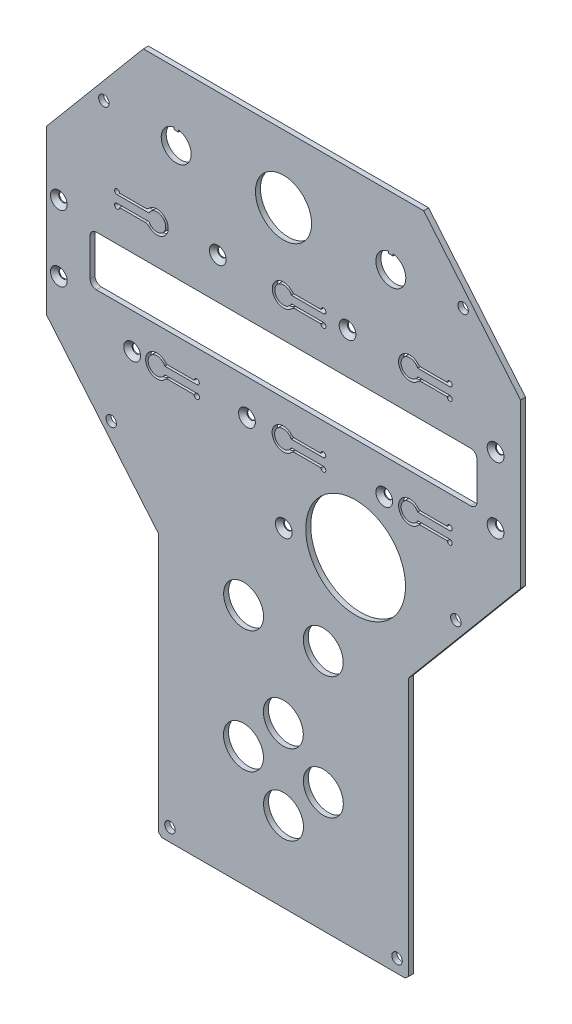
from build123d import *

# Parameters (mm, degrees)
RESSALTO_EXTRUS_O1_DEPTH                      = 2
CORTE_EXTRUS_O1_REACH                         = 4
ESBO_O2_R                                     = 2.1
CORTE_EXTRUS_O2_REACH                         = 4
CORTE_EXTRUS_O3_REACH                         = 4
ESBO_O4_R                                     = 20
CORTE_EXTRUS_O4_REACH                         = 4
ESBO_O5_R                                     = 8
ESBO_O5_R_2                                   = 11.25
ESCAREADO_PARA_PARAFUSO_ALLEN_SEXTAV_2_COUNT  = 2
ESCAREADO_PARA_PARAFUSO_ALLEN_SEXTAV_2_PITCH  = 26.5
ESCAREADO_PARA_PARAFUSO_ALLEN_SEXTAV_3_COUNT  = 2
ESCAREADO_PARA_PARAFUSO_ALLEN_SEXTAV_3_PITCH  = 47.918783057
ESCAREADO_PARA_PARAFUSO_ALLEN_SEXTAV_4_COUNT  = 2
ESCAREADO_PARA_PARAFUSO_ALLEN_SEXTAV_4_PITCH  = 84.354894452
ESCAREADO_PARA_PARAFUSO_ALLEN_SEXTAV_5_COUNT  = 2
ESCAREADO_PARA_PARAFUSO_ALLEN_SEXTAV_5_PITCH  = 135.769067452
ESCAREADO_PARA_PARAFUSO_ALLEN_SEXTAV_6_COUNT  = 2
ESCAREADO_PARA_PARAFUSO_ALLEN_SEXTAV_6_PITCH  = 176.995056428
ESCAREADO_PARA_PARAFUSO_ALLEN_SEXTAV_7_COUNT  = 2
ESCAREADO_PARA_PARAFUSO_ALLEN_SEXTAV_7_PITCH  = 175
ESCAREADO_PARA_PARAFUSO_ALLEN_SEXTAV_8_COUNT  = 2
ESCAREADO_PARA_PARAFUSO_ALLEN_SEXTAV_8_PITCH  = 116.384068539
ESCAREADO_PARA_PARAFUSO_ALLEN_SEXTAV_9_COUNT  = 2
ESCAREADO_PARA_PARAFUSO_ALLEN_SEXTAV_9_PITCH  = 64.945475466
ESCAREADO_PARA_PARAFUSO_ALLEN_SEXTAV_10_COUNT = 2
ESCAREADO_PARA_PARAFUSO_ALLEN_SEXTAV_10_PITCH = 113.39334618
CORTE_EXTRUS_O5_DEPTH                         = 10
FILETE1_R                                     = 2


with BuildPart() as part:
    # Esboço1 → Ressalto-extrusão1 (new body)
    with BuildSketch(Plane.XY):
        Polygon((55.321046002, 133.809611411), (-57.006999458, 133.809611411), (-95.842976728, 87.526695978), (-95.842976728, 22.140182404), (-50.842976728, -31.488729263), (-50.842976728, -135.082673958), (-49.522853837, -136.190388589), (47.836900381, -136.190388589), (49.157023272, -135.082673958), (49.157023272, -31.488729263), (94.157023272, 22.140182404), (94.157023272, 87.526695978), align=None)
    extrude(amount=RESSALTO_EXTRUS_O1_DEPTH)

    # Esboço2 → Corte-extrusão1 (cut, up to next)
    with BuildSketch(Plane.XY.offset(2), mode=Mode.PRIVATE) as corte_extrus_o1_sk1:
        with Locations((-72.814392548, 107.949888211)):
            Circle(ESBO_O2_R)
    corte_extrus_o1_tool1 = extrude(corte_extrus_o1_sk1.sketch, amount=-CORTE_EXTRUS_O1_REACH, mode=Mode.PRIVATE) & part.part
    add(corte_extrus_o1_tool1.solids().sort_by_distance((-72.814393, 107.949888, 2))[0], mode=Mode.SUBTRACT)
    # Esboço2 → Corte-extrusão1 (cut, up to next)
    with BuildSketch(Plane.XY.offset(2), mode=Mode.PRIVATE) as corte_extrus_o1_sk2:
        with Locations((-46.342976728, -130.964393909)):
            Circle(ESBO_O2_R)
    corte_extrus_o1_tool2 = extrude(corte_extrus_o1_sk2.sketch, amount=-CORTE_EXTRUS_O1_REACH, mode=Mode.PRIVATE) & part.part
    add(corte_extrus_o1_tool2.solids().sort_by_distance((-46.342977, -130.964394, 2))[0], mode=Mode.SUBTRACT)
    # Esboço2 → Corte-extrusão1 (cut, up to next)
    with BuildSketch(Plane.XY.offset(2), mode=Mode.PRIVATE) as corte_extrus_o1_sk3:
        with Locations((44.657023272, -130.964393909)):
            Circle(ESBO_O2_R)
    corte_extrus_o1_tool3 = extrude(corte_extrus_o1_sk3.sketch, amount=-CORTE_EXTRUS_O1_REACH, mode=Mode.PRIVATE) & part.part
    add(corte_extrus_o1_tool3.solids().sort_by_distance((44.657023, -130.964394, 2))[0], mode=Mode.SUBTRACT)
    # Esboço2 → Corte-extrusão1 (cut, up to next)
    with BuildSketch(Plane.XY.offset(2), mode=Mode.PRIVATE) as corte_extrus_o1_sk4:
        with Locations((71.128439092, 107.949888211)):
            Circle(ESBO_O2_R)
    corte_extrus_o1_tool4 = extrude(corte_extrus_o1_sk4.sketch, amount=-CORTE_EXTRUS_O1_REACH, mode=Mode.PRIVATE) & part.part
    add(corte_extrus_o1_tool4.solids().sort_by_distance((71.128439, 107.949888, 2))[0], mode=Mode.SUBTRACT)
    # Esboço2 → Corte-extrusão1 (cut, up to next)
    with BuildSketch(Plane.XY.offset(2), mode=Mode.PRIVATE) as corte_extrus_o1_sk5:
        with Locations((-69.895776734, -1.781729186)):
            Circle(ESBO_O2_R)
    corte_extrus_o1_tool5 = extrude(corte_extrus_o1_sk5.sketch, amount=-CORTE_EXTRUS_O1_REACH, mode=Mode.PRIVATE) & part.part
    add(corte_extrus_o1_tool5.solids().sort_by_distance((-69.895777, -1.781729, 2))[0], mode=Mode.SUBTRACT)
    # Esboço2 → Corte-extrusão1 (cut, up to next)
    with BuildSketch(Plane.XY.offset(2), mode=Mode.PRIVATE) as corte_extrus_o1_sk6:
        with Locations((68.209823278, -1.781729186)):
            Circle(ESBO_O2_R)
    corte_extrus_o1_tool6 = extrude(corte_extrus_o1_sk6.sketch, amount=-CORTE_EXTRUS_O1_REACH, mode=Mode.PRIVATE) & part.part
    add(corte_extrus_o1_tool6.solids().sort_by_distance((68.209823, -1.781729, 2))[0], mode=Mode.SUBTRACT)

    # Esboço3 → Corte-extrusão2 (cut, up to next)
    with BuildSketch(Plane.XY.offset(2), mode=Mode.PRIVATE) as corte_extrus_o2_sk1:
        with BuildLine():
            Line((-75.842976728, 40.809611411), (74.157023272, 40.809611411))
            ThreePointArc((74.157023272, 40.809611411), (75.924790225, 41.541844458), (76.657023272, 43.309611411))
            Line((76.657023272, 43.309611411), (76.657023272, 58.309611411))
            ThreePointArc((76.657023272, 58.309611411), (75.924790225, 60.077378364), (74.157023272, 60.809611411))
            Line((74.157023272, 60.809611411), (-75.842976728, 60.809611411))
            ThreePointArc((-75.842976728, 60.809611411), (-77.610743681, 60.077378364), (-78.342976728, 58.309611411))
            Line((-78.342976728, 58.309611411), (-78.342976728, 43.309611411))
            ThreePointArc((-78.342976728, 43.309611411), (-77.610743681, 41.541844458), (-75.842976728, 40.809611411))
        make_face()
    corte_extrus_o2_tool1 = extrude(corte_extrus_o2_sk1.sketch, amount=-CORTE_EXTRUS_O2_REACH, mode=Mode.PRIVATE) & part.part
    add(corte_extrus_o2_tool1.solids().sort_by_distance((-0.842977, 50.809611, 2))[0], mode=Mode.SUBTRACT)

    # Esboço4 → Corte-extrusão3 (cut, up to next)
    with BuildSketch(Plane.XY.offset(2), mode=Mode.PRIVATE) as corte_extrus_o3_sk1:
        with Locations((28.056326272, -0.190388589)):
            Circle(ESBO_O4_R)
    corte_extrus_o3_tool1 = extrude(corte_extrus_o3_sk1.sketch, amount=-CORTE_EXTRUS_O3_REACH, mode=Mode.PRIVATE) & part.part
    add(corte_extrus_o3_tool1.solids().sort_by_distance((28.056326, -0.190389, 2))[0], mode=Mode.SUBTRACT)

    # Esboço5 → Corte-extrusão4 (cut, up to next)
    with BuildSketch(Plane.XY.offset(2), mode=Mode.PRIVATE) as corte_extrus_o4_sk1:
        with Locations((-16.894876728, -88.105888589)):
            Circle(ESBO_O5_R)
    corte_extrus_o4_tool1 = extrude(corte_extrus_o4_sk1.sketch, amount=-CORTE_EXTRUS_O4_REACH, mode=Mode.PRIVATE) & part.part
    add(corte_extrus_o4_tool1.solids().sort_by_distance((-16.894877, -88.105889, 2))[0], mode=Mode.SUBTRACT)
    # Esboço5 → Corte-extrusão4 (cut, up to next)
    with BuildSketch(Plane.XY.offset(2), mode=Mode.PRIVATE) as corte_extrus_o4_sk2:
        with Locations((15.122923272, -88.105888589)):
            Circle(ESBO_O5_R)
    corte_extrus_o4_tool2 = extrude(corte_extrus_o4_sk2.sketch, amount=-CORTE_EXTRUS_O4_REACH, mode=Mode.PRIVATE) & part.part
    add(corte_extrus_o4_tool2.solids().sort_by_distance((15.122923, -88.105889, 2))[0], mode=Mode.SUBTRACT)
    # Esboço5 → Corte-extrusão4 (cut, up to next)
    with BuildSketch(Plane.XY.offset(2), mode=Mode.PRIVATE) as corte_extrus_o4_sk3:
        with Locations((-0.842976728, -104.141188589)):
            Circle(ESBO_O5_R)
    corte_extrus_o4_tool3 = extrude(corte_extrus_o4_sk3.sketch, amount=-CORTE_EXTRUS_O4_REACH, mode=Mode.PRIVATE) & part.part
    add(corte_extrus_o4_tool3.solids().sort_by_distance((-0.842977, -104.141189, 2))[0], mode=Mode.SUBTRACT)
    # Esboço5 → Corte-extrusão4 (cut, up to next)
    with BuildSketch(Plane.XY.offset(2), mode=Mode.PRIVATE) as corte_extrus_o4_sk4:
        with Locations((-0.909676728, -72.123388589)):
            Circle(ESBO_O5_R)
    corte_extrus_o4_tool4 = extrude(corte_extrus_o4_sk4.sketch, amount=-CORTE_EXTRUS_O4_REACH, mode=Mode.PRIVATE) & part.part
    add(corte_extrus_o4_tool4.solids().sort_by_distance((-0.909677, -72.123389, 2))[0], mode=Mode.SUBTRACT)
    # Esboço5 → Corte-extrusão4 (cut, up to next)
    with BuildSketch(Plane.XY.offset(2), mode=Mode.PRIVATE) as corte_extrus_o4_sk5:
        with Locations((-16.835676728, -39.139288589)):
            Circle(ESBO_O5_R)
    corte_extrus_o4_tool5 = extrude(corte_extrus_o4_sk5.sketch, amount=-CORTE_EXTRUS_O4_REACH, mode=Mode.PRIVATE) & part.part
    add(corte_extrus_o4_tool5.solids().sort_by_distance((-16.835677, -39.139289, 2))[0], mode=Mode.SUBTRACT)
    # Esboço5 → Corte-extrusão4 (cut, up to next)
    with BuildSketch(Plane.XY.offset(2), mode=Mode.PRIVATE) as corte_extrus_o4_sk6:
        with Locations((15.081923272, -39.110788589)):
            Circle(ESBO_O5_R)
    corte_extrus_o4_tool6 = extrude(corte_extrus_o4_sk6.sketch, amount=-CORTE_EXTRUS_O4_REACH, mode=Mode.PRIVATE) & part.part
    add(corte_extrus_o4_tool6.solids().sort_by_distance((15.081923, -39.110789, 2))[0], mode=Mode.SUBTRACT)
    # Esboço5 → Corte-extrusão4 (cut, up to next)
    with BuildSketch(Plane.XY.offset(2), mode=Mode.PRIVATE) as corte_extrus_o4_sk7:
        with Locations((-0.842976728, 106.809611411)):
            Circle(ESBO_O5_R_2)
    corte_extrus_o4_tool7 = extrude(corte_extrus_o4_sk7.sketch, amount=-CORTE_EXTRUS_O4_REACH, mode=Mode.PRIVATE) & part.part
    add(corte_extrus_o4_tool7.solids().sort_by_distance((-0.842977, 106.809611, 2))[0], mode=Mode.SUBTRACT)
    # Esboço5 → Corte-extrusão4 (cut, up to next)
    with BuildSketch(Plane.XY.offset(2), mode=Mode.PRIVATE) as corte_extrus_o4_sk8:
        with BuildLine():
            Line((-44.742976728, 112.741727391), (-44.742976728, 111.941727391))
            Line((-44.742976728, 111.941727391), (-42.942976728, 111.941727391))
            Line((-42.942976728, 111.941727391), (-42.942976728, 112.741727391))
            ThreePointArc((-42.942976728, 112.741727391), (-43.842976728, 100.809611411), (-44.742976728, 112.741727391))
        make_face()
    corte_extrus_o4_tool8 = extrude(corte_extrus_o4_sk8.sketch, amount=-CORTE_EXTRUS_O4_REACH, mode=Mode.PRIVATE) & part.part
    add(corte_extrus_o4_tool8.solids().sort_by_distance((-43.842977, 106.733858, 2))[0], mode=Mode.SUBTRACT)
    # Esboço5 → Corte-extrusão4 (cut, up to next)
    with BuildSketch(Plane.XY.offset(2), mode=Mode.PRIVATE) as corte_extrus_o4_sk9:
        with BuildLine():
            Line((41.257023272, 112.741727391), (41.257023272, 111.941727391))
            Line((41.257023272, 111.941727391), (43.057023272, 111.941727391))
            Line((43.057023272, 111.941727391), (43.057023272, 112.741727391))
            ThreePointArc((43.057023272, 112.741727391), (42.157023272, 100.809611411), (41.257023272, 112.741727391))
        make_face()
    corte_extrus_o4_tool9 = extrude(corte_extrus_o4_sk9.sketch, amount=-CORTE_EXTRUS_O4_REACH, mode=Mode.PRIVATE) & part.part
    add(corte_extrus_o4_tool9.solids().sort_by_distance((42.157023, 106.733858, 2))[0], mode=Mode.SUBTRACT)

    # Esboço11 → Escareado para parafuso Allen sextavado escareado de M32 (revolve, cut)
    with BuildSketch(Plane(origin=(-90.868976728, 64.471011411, 2), x_dir=(0, -1, 0), z_dir=(1, 0, 0))):
        Polygon((0, 0), (0, 2), (1.7, 2), (1.7, 1.66), (3.36, 0), align=None)
    escareado_para_parafuso_allen_sextavado = revolve(axis=Axis((-90.868976728, 64.471011411, 8.35), (0, 0, -1)), mode=Mode.SUBTRACT)

    # Escareado para parafuso Allen sextav 2: Escareado para parafuso Allen sextavado escareado de M32 ×2
    with Locations(*[(0, -i * ESCAREADO_PARA_PARAFUSO_ALLEN_SEXTAV_2_PITCH, 0) for i in range(1, ESCAREADO_PARA_PARAFUSO_ALLEN_SEXTAV_2_COUNT)]):
        add(escareado_para_parafuso_allen_sextavado, mode=Mode.SUBTRACT)

    # Escareado para parafuso Allen sextav 3: Escareado para parafuso Allen sextavado escareado de M32 ×2
    with Locations(*[Vector(0.613251976, -0.789887343, 0) * (i * ESCAREADO_PARA_PARAFUSO_ALLEN_SEXTAV_3_PITCH) for i in range(1, ESCAREADO_PARA_PARAFUSO_ALLEN_SEXTAV_3_COUNT)]):
        add(escareado_para_parafuso_allen_sextavado, mode=Mode.SUBTRACT)

    # Escareado para parafuso Allen sextav 4: Escareado para parafuso Allen sextavado escareado de M32 ×2
    with Locations(*[Vector(0.893680068, -0.448704731, 0) * (i * ESCAREADO_PARA_PARAFUSO_ALLEN_SEXTAV_4_PITCH) for i in range(1, ESCAREADO_PARA_PARAFUSO_ALLEN_SEXTAV_4_COUNT)]):
        add(escareado_para_parafuso_allen_sextavado, mode=Mode.SUBTRACT)

    # Escareado para parafuso Allen sextav 5: Escareado para parafuso Allen sextavado escareado de M32 ×2
    with Locations(*[Vector(0.960353411, -0.278785447, 0) * (i * ESCAREADO_PARA_PARAFUSO_ALLEN_SEXTAV_5_PITCH) for i in range(1, ESCAREADO_PARA_PARAFUSO_ALLEN_SEXTAV_5_COUNT)]):
        add(escareado_para_parafuso_allen_sextavado, mode=Mode.SUBTRACT)

    # Escareado para parafuso Allen sextav 6: Escareado para parafuso Allen sextavado escareado de M32 ×2
    with Locations(*[Vector(0.98872818, -0.149721696, 0) * (i * ESCAREADO_PARA_PARAFUSO_ALLEN_SEXTAV_6_PITCH) for i in range(1, ESCAREADO_PARA_PARAFUSO_ALLEN_SEXTAV_6_COUNT)]):
        add(escareado_para_parafuso_allen_sextavado, mode=Mode.SUBTRACT)

    # Escareado para parafuso Allen sextav 7: Escareado para parafuso Allen sextavado escareado de M32 ×2
    with Locations(*[(i * ESCAREADO_PARA_PARAFUSO_ALLEN_SEXTAV_7_PITCH, 0, 0) for i in range(1, ESCAREADO_PARA_PARAFUSO_ALLEN_SEXTAV_7_COUNT)]):
        add(escareado_para_parafuso_allen_sextavado, mode=Mode.SUBTRACT)

    # Escareado para parafuso Allen sextav 8: Escareado para parafuso Allen sextavado escareado de M32 ×2
    with Locations(*[Vector(0.994001416, 0.109367203, 0) * (i * ESCAREADO_PARA_PARAFUSO_ALLEN_SEXTAV_8_PITCH) for i in range(1, ESCAREADO_PARA_PARAFUSO_ALLEN_SEXTAV_8_COUNT)]):
        add(escareado_para_parafuso_allen_sextavado, mode=Mode.SUBTRACT)

    # Escareado para parafuso Allen sextav 9: Escareado para parafuso Allen sextavado escareado de M32 ×2
    with Locations(*[Vector(0.98060609, 0.195989019, 0) * (i * ESCAREADO_PARA_PARAFUSO_ALLEN_SEXTAV_9_PITCH) for i in range(1, ESCAREADO_PARA_PARAFUSO_ALLEN_SEXTAV_9_COUNT)]):
        add(escareado_para_parafuso_allen_sextavado, mode=Mode.SUBTRACT)

    # Escareado para parafuso Allen sextav 10: Escareado para parafuso Allen sextavado escareado de M32 ×2
    with Locations(*[Vector(0.794899268, -0.606741423, 0) * (i * ESCAREADO_PARA_PARAFUSO_ALLEN_SEXTAV_10_PITCH) for i in range(1, ESCAREADO_PARA_PARAFUSO_ALLEN_SEXTAV_10_COUNT)]):
        add(escareado_para_parafuso_allen_sextavado, mode=Mode.SUBTRACT)

    # Esboço12 → Corte-extrusão5 (cut)
    with BuildSketch(Plane.XY.offset(2)):
        with BuildLine():
            Line((52.929300932, 28.019611411), (65.767023272, 28.019611411))
            ThreePointArc((65.767023272, 28.019611411), (66.474130053, 29.726718193), (64.767023272, 29.019611411))
            Line((64.767023272, 29.019611411), (53.508680659, 29.019611411))
            ThreePointArc((53.508680659, 29.019611411), (45.267023272, 26.519611411), (53.508680659, 24.019611411))
            Line((53.508680659, 24.019611411), (64.767023272, 24.019611411))
            ThreePointArc((64.767023272, 24.019611411), (66.474130053, 23.31250463), (65.767023272, 25.019611411))
            Line((65.767023272, 25.019611411), (52.929300932, 25.019611411))
            ThreePointArc((52.929300932, 25.019611411), (46.267023272, 26.519611411), (52.929300932, 28.019611411))
        make_face()
        with BuildLine():
            Line((2.259300932, 28.019611411), (15.097023272, 28.019611411))
            ThreePointArc((15.097023272, 28.019611411), (15.804130053, 29.726718193), (14.097023272, 29.019611411))
            Line((14.097023272, 29.019611411), (2.838680659, 29.019611411))
            ThreePointArc((2.838680659, 29.019611411), (-5.402976728, 26.519611411), (2.838680659, 24.019611411))
            Line((2.838680659, 24.019611411), (14.097023272, 24.019611411))
            ThreePointArc((14.097023272, 24.019611411), (15.804130053, 23.31250463), (15.097023272, 25.019611411))
            Line((15.097023272, 25.019611411), (2.259300932, 25.019611411))
            ThreePointArc((2.259300932, 25.019611411), (-4.402976728, 26.519611411), (2.259300932, 28.019611411))
        make_face()
        with BuildLine():
            Line((-48.410699068, 28.019611411), (-35.572976728, 28.019611411))
            ThreePointArc((-35.572976728, 28.019611411), (-34.865869947, 29.726718193), (-36.572976728, 29.019611411))
            Line((-36.572976728, 29.019611411), (-47.831319341, 29.019611411))
            ThreePointArc((-47.831319341, 29.019611411), (-56.072976728, 26.519611411), (-47.831319341, 24.019611411))
            Line((-47.831319341, 24.019611411), (-36.653425887, 24.019611411))
            ThreePointArc((-36.653425887, 24.019611411), (-34.675928196, 23.417386939), (-35.982085986, 25.019611411))
            Line((-35.982085986, 25.019611411), (-48.410699068, 25.019611411))
            ThreePointArc((-48.410699068, 25.019611411), (-55.072976728, 26.519611411), (-48.410699068, 28.019611411))
        make_face()
        with BuildLine():
            Line((2.329300932, 77.979611411), (15.167023272, 77.979611411))
            ThreePointArc((15.167023272, 77.979611411), (15.874130053, 79.686718193), (14.167023272, 78.979611411))
            Line((14.167023272, 78.979611411), (2.908680659, 78.979611411))
            ThreePointArc((2.908680659, 78.979611411), (-5.332976728, 76.479611411), (2.908680659, 73.979611411))
            Line((2.908680659, 73.979611411), (14.167023272, 73.979611411))
            ThreePointArc((14.167023272, 73.979611411), (15.874130053, 73.27250463), (15.167023272, 74.979611411))
            Line((15.167023272, 74.979611411), (2.329300932, 74.979611411))
            ThreePointArc((2.329300932, 74.979611411), (-4.332976728, 76.479611411), (2.329300932, 77.979611411))
        make_face()
        with BuildLine():
            Line((52.929300932, 77.979611411), (65.767023272, 77.979611411))
            ThreePointArc((65.767023272, 77.979611411), (66.474130053, 79.686718193), (64.767023272, 78.979611411))
            Line((64.767023272, 78.979611411), (53.508680659, 78.979611411))
            ThreePointArc((53.508680659, 78.979611411), (45.267023272, 76.479611411), (53.508680659, 73.979611411))
            Line((53.508680659, 73.979611411), (64.767023272, 73.979611411))
            ThreePointArc((64.767023272, 73.979611411), (66.474130053, 73.27250463), (65.767023272, 74.979611411))
            Line((65.767023272, 74.979611411), (52.929300932, 74.979611411))
            ThreePointArc((52.929300932, 74.979611411), (46.267023272, 76.479611411), (52.929300932, 77.979611411))
        make_face()
        with BuildLine():
            Line((-54.695254388, 77.979611411), (-67.532976728, 77.979611411))
            ThreePointArc((-67.532976728, 77.979611411), (-68.240083509, 79.686718193), (-66.532976728, 78.979611411))
            Line((-66.532976728, 78.979611411), (-55.274634115, 78.979611411))
            ThreePointArc((-55.274634115, 78.979611411), (-47.032976728, 76.479611411), (-55.274634115, 73.979611411))
            Line((-55.274634115, 73.979611411), (-66.532976728, 73.979611411))
            ThreePointArc((-66.532976728, 73.979611411), (-68.240083509, 73.27250463), (-67.532976728, 74.979611411))
            Line((-67.532976728, 74.979611411), (-54.695254388, 74.979611411))
            ThreePointArc((-54.695254388, 74.979611411), (-48.032976728, 76.479611411), (-54.695254388, 77.979611411))
        make_face()
    extrude(amount=-CORTE_EXTRUS_O5_DEPTH, mode=Mode.SUBTRACT)

    # Filete1
    filete1_edges = [part.edges().sort_by_distance(p)[0] for p in [
        (53.508680659, 29.019611411, 1),
        (-47.831319341, 24.019611411, 1),
        (-47.831319341, 29.019611411, 1),
        (-55.274634115, 78.979611411, 1),
        (-55.274634115, 73.979611411, 1),
        (2.908680659, 73.979611411, 1),
        (2.908680659, 78.979611411, 1),
        (53.508680659, 73.979611411, 1),
        (53.508680659, 78.979611411, 1),
        (2.838680659, 24.019611411, 1),
        (2.838680659, 29.019611411, 1),
    ]]
    fillet(filete1_edges, radius=FILETE1_R)


solid = part.part
